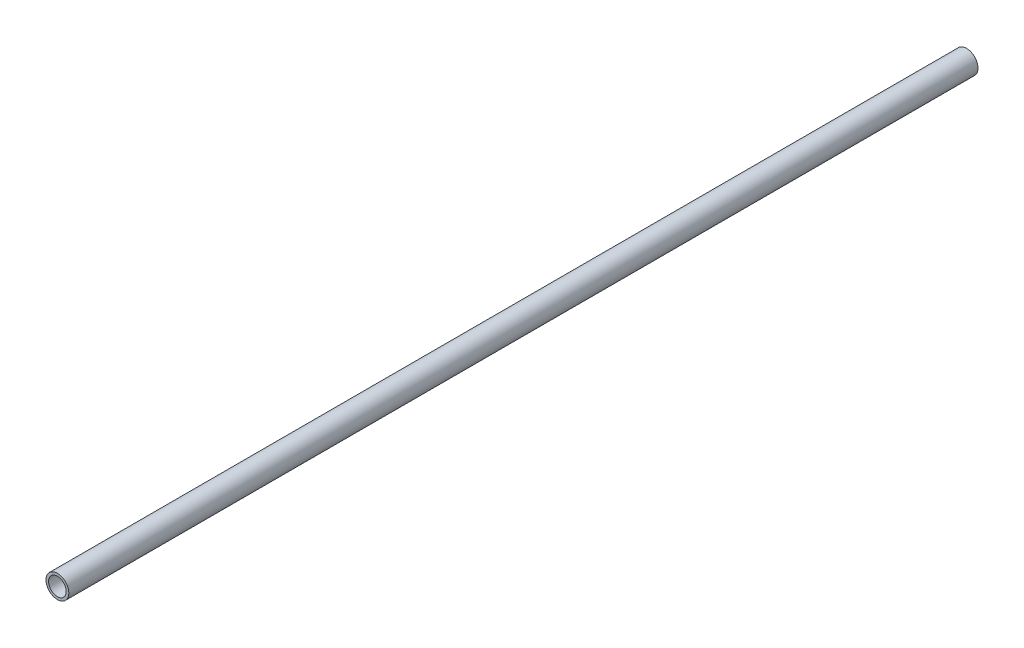
from build123d import *

# Parameters (mm, degrees)
SKETCH1_R           = 16.891
SKETCH1_R_2         = 13.081
BOSS_EXTRUDE1_DEPTH = 1346.2


with BuildPart() as part:
    # Sketch1 → Boss-Extrude1 (new body)
    with BuildSketch(Plane.XY):
        Circle(SKETCH1_R)
        Circle(SKETCH1_R_2, mode=Mode.SUBTRACT)
    extrude(amount=BOSS_EXTRUDE1_DEPTH)


solid = part.part
